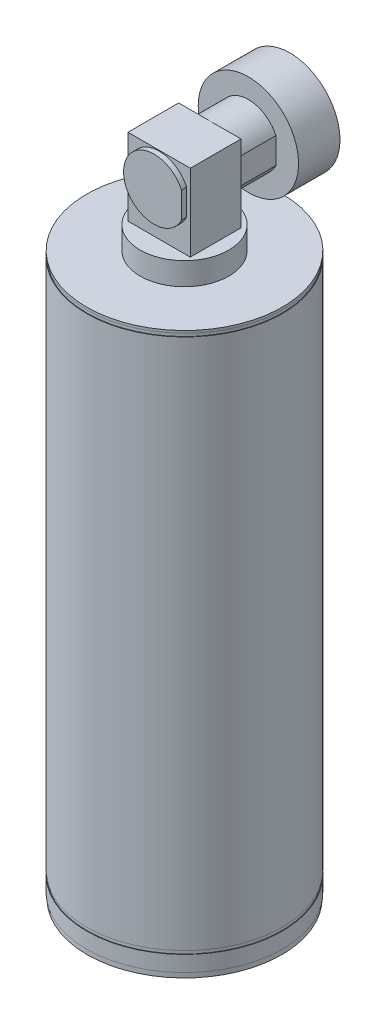
from build123d import *

# Parameters (mm, degrees)
SKETCH6_R           = 134.318809958
EXTRUDE1_DEPTH      = 7.0358
SKETCH7_R           = 135.080809958
EXTRUDE2_DEPTH      = 21.6548
SKETCH8_R           = 134.318809958
EXTRUDE3_DEPTH      = 4.6188
SKETCH9_R           = 135.080809958
EXTRUDE4_DEPTH      = 733.4758
SKETCH10_R          = 134.318809958
EXTRUDE5_DEPTH      = 4.445
SKETCH11_R          = 135.080809958
EXTRUDE6_DEPTH      = 3.26898
SKETCH12_R          = 61.143546623
EXTRUDE7_DEPTH      = 31.20898
SKETCH13_W          = 86
SKETCH13_H          = 70
EXTRUDE8_DEPTH      = 106.29184
EXTRUDE9_DEPTH      = 7.07898
EXTRUDE9_DEPTH_BACK = 123.19
SKETCH15_R          = 69.240552209
EXTRUDE10_DEPTH     = 57.15
SKETCH16_R          = 31.191641703
CUT_EXTRUDE1_DEPTH  = 758.28398


with BuildPart() as part:
    # Sketch6 → Extrude1 (new body)
    with BuildSketch(Plane(origin=(0, 0, 0), x_dir=(1, 0, 0), z_dir=(0, 1, 0))):
        Circle(SKETCH6_R)
    extrude(amount=EXTRUDE1_DEPTH)

    # Sketch7 → Extrude2 (add)
    with BuildSketch(Plane(origin=(0, 7.0358, 0), x_dir=(-1, 0, 0), z_dir=(0, 1, 0))):
        Circle(SKETCH7_R)
    extrude(amount=EXTRUDE2_DEPTH)

    # Sketch8 → Extrude3 (add)
    with BuildSketch(Plane(origin=(0, 28.6906, 0), x_dir=(-1, 0, 0), z_dir=(0, 1, 0))):
        Circle(SKETCH8_R)
    extrude(amount=EXTRUDE3_DEPTH)

    # Sketch9 → Extrude4 (add)
    with BuildSketch(Plane(origin=(0, 33.3094, 0), x_dir=(-1, 0, 0), z_dir=(0, 1, 0))):
        Circle(SKETCH9_R)
    extrude(amount=EXTRUDE4_DEPTH)

    # Sketch10 → Extrude5 (add)
    with BuildSketch(Plane(origin=(0, 766.7852, 0), x_dir=(-1, 0, 0), z_dir=(0, 1, 0))):
        Circle(SKETCH10_R)
    extrude(amount=EXTRUDE5_DEPTH)

    # Sketch11 → Extrude6 (add)
    with BuildSketch(Plane(origin=(0, 771.2302, 0), x_dir=(-1, 0, 0), z_dir=(0, 1, 0))):
        Circle(SKETCH11_R)
    extrude(amount=EXTRUDE6_DEPTH)

    # Sketch12 → Extrude7 (add)
    with BuildSketch(Plane(origin=(0, 774.49918, 0), x_dir=(-1, 0, 0), z_dir=(0, 1, 0))):
        Circle(SKETCH12_R)
    extrude(amount=EXTRUDE7_DEPTH)

    # Sketch13 → Extrude8 (add)
    with BuildSketch(Plane(origin=(0, 805.70816, 0), x_dir=(-1, 0, 0), z_dir=(0, 1, 0))):
        with Locations((0, 4.8e-08)):
            Rectangle(SKETCH13_W, SKETCH13_H)
    extrude(amount=EXTRUDE8_DEPTH)

    # Sketch14 → Extrude9 (add, two sides)
    with BuildSketch(Plane.XY.offset(35.000000048)) as extrude9_sk:
        with BuildLine():
            Line((37.999996487, 886.888547526), (37.999996487, 851.111452474))
            ThreePointArc((37.999996487, 851.111452474), (-41.9999984, 869), (37.999996487, 886.888547526))
        make_face()
    extrude(amount=EXTRUDE9_DEPTH)
    extrude(extrude9_sk.sketch, amount=-EXTRUDE9_DEPTH_BACK)

    # Sketch15 → Extrude10 (add)
    with BuildSketch(Plane(origin=(0, 0, -88.189999952), x_dir=(-1, 0, 0), z_dir=(0, 0, -1))):
        with Locations((0, 869)):
            Circle(SKETCH15_R)
    extrude(amount=EXTRUDE10_DEPTH)

    # Sketch16 → Cut-Extrude1 (cut)
    with BuildSketch(Plane.XZ):
        Circle(SKETCH16_R)
    extrude(amount=-CUT_EXTRUDE1_DEPTH, mode=Mode.SUBTRACT)


solid = part.part
